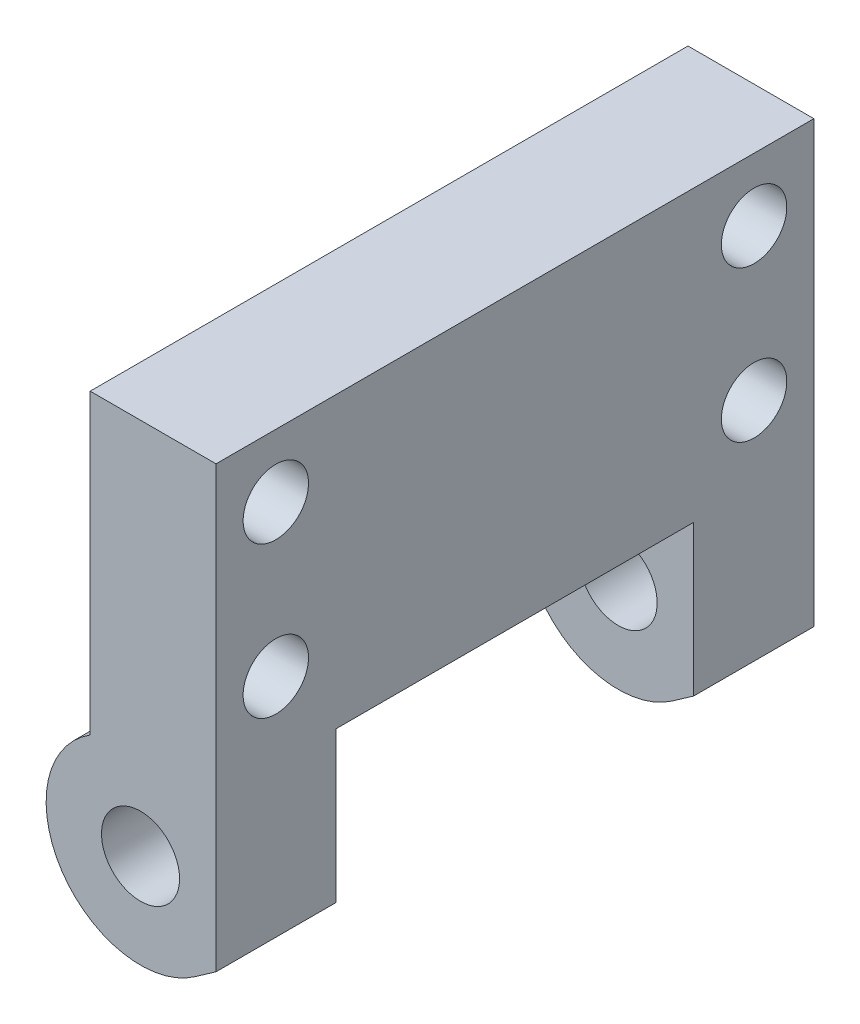
from build123d import *

# Parameters (mm, degrees)
SKETCH1_R           = 3.1
BOSS_EXTRUDE1_DEPTH = 47.5
SKETCH2_W           = 28.4
SKETCH2_H           = 18.032695685
CUT_EXTRUDE1_DEPTH  = 14.5
SKETCH3_R           = 2.6
CUT_EXTRUDE2_DEPTH  = 11


with BuildPart() as part:
    # Sketch1 → Boss-Extrude1 (new body)
    with BuildSketch(Plane.XY):
        with BuildLine():
            Line((-4, 6.34428877), (-4, 30))
            Line((-4, 30), (6, 30))
            Line((6, 30), (6, -4.954564186))
            Line((6, -4.954564186), (4.301823273, -6.143640332))
            ThreePointArc((4.301823273, -6.143640332), (-6.245787992, -4.152123837), (-4, 6.34428877))
        make_face()
        Circle(SKETCH1_R, mode=Mode.SUBTRACT)
    extrude(amount=BOSS_EXTRUDE1_DEPTH)

    # Sketch2 → Cut-Extrude1 (cut, through all)
    with BuildSketch(Plane(origin=(6, 0, 0), x_dir=(0, 0, -1), z_dir=(1, 0, 0))):
        with Locations((-23.75, -2.016347843)):
            Rectangle(SKETCH2_W, SKETCH2_H)
    extrude(amount=-CUT_EXTRUDE1_DEPTH, mode=Mode.SUBTRACT)

    # Sketch3 → Cut-Extrude2 (cut, through all)
    with BuildSketch(Plane.ZY.offset(4)):
        with Locations((4.75, 25)):
            Circle(SKETCH3_R)
        with Locations((4.75, 13)):
            Circle(SKETCH3_R)
        with Locations((42.75, 25)):
            Circle(SKETCH3_R)
        with Locations((42.75, 13)):
            Circle(SKETCH3_R)
    extrude(amount=-CUT_EXTRUDE2_DEPTH, mode=Mode.SUBTRACT)


solid = part.part
